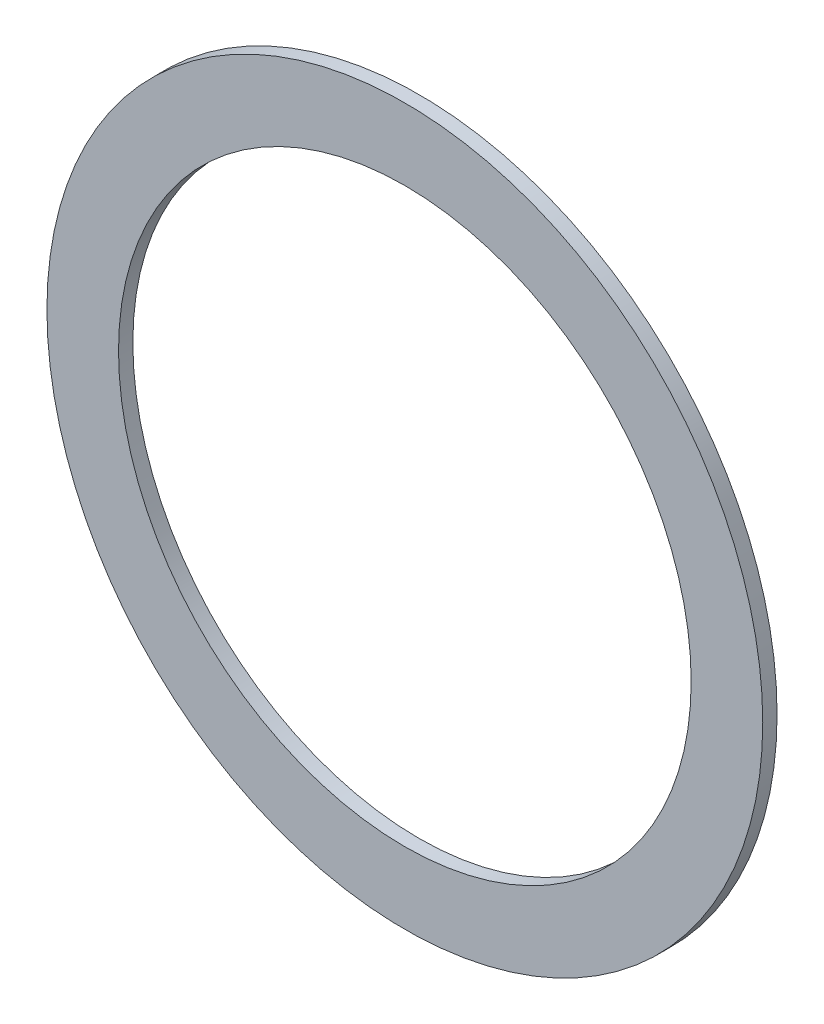
from build123d import *

# Parameters (mm, degrees)
SKETCH1_R          = 25
SKETCH1_R_2        = 20
BASE_EXTRUDE_DEPTH = 1


with BuildPart() as part:
    # Sketch1 → Base-Extrude (new body)
    with BuildSketch(Plane.XY):
        Circle(SKETCH1_R)
        Circle(SKETCH1_R_2, mode=Mode.SUBTRACT)
    extrude(amount=BASE_EXTRUDE_DEPTH)


solid = part.part
